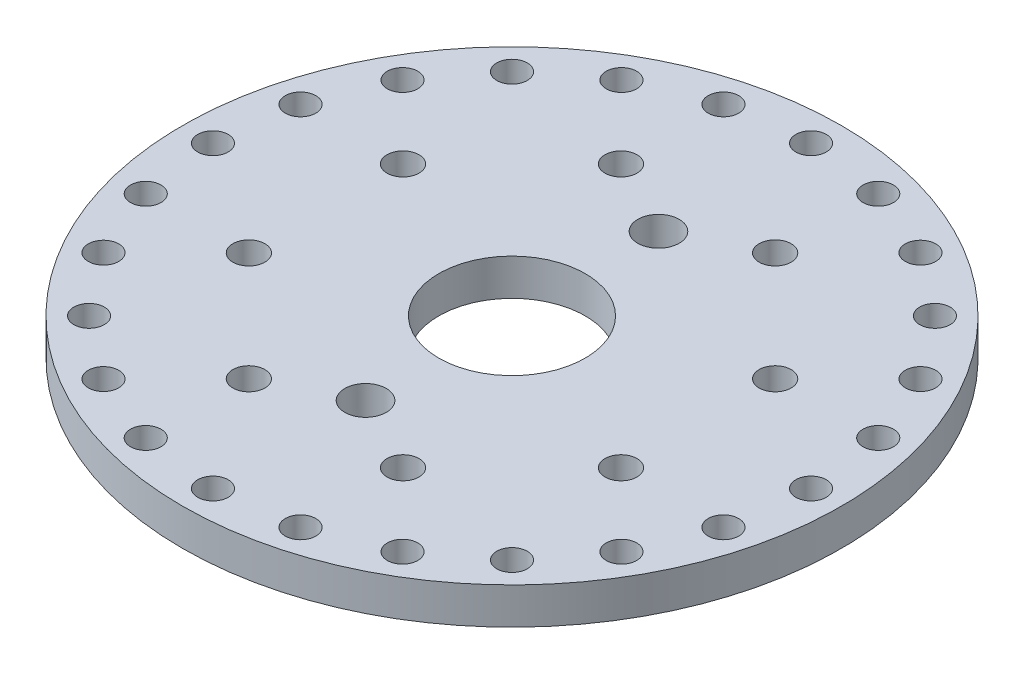
from build123d import *

# Parameters (mm, degrees)
SKETCH8_R           = 27
BOSS_EXTRUDE1_DEPTH = 3
CUT_EXTRUDE1_REACH  = 109.975
SKETCH6_R           = 6
CUT_EXTRUDE2_REACH  = 109.975
SKETCH7_R           = 1.7
CUT_EXTRUDE3_REACH  = 109.975
SKETCH9_R           = 1.25
CUT_EXTRUDE4_REACH  = 109.975
SKETCH11_R          = 1.3125


with BuildPart() as part:
    # Sketch8 → Boss-Extrude1 (new body)
    with BuildSketch(Plane(origin=(0, 0, 0), x_dir=(1, 0, 0), z_dir=(0, 1, 0))):
        with Locations((49.061012395, 49.578499829)):
            Circle(SKETCH8_R)
    extrude(amount=BOSS_EXTRUDE1_DEPTH)

    # Sketch6 → Cut-Extrude1 (cut, up to next)
    with BuildSketch(Plane(origin=(0, 0, 0), x_dir=(1, 0, 0), z_dir=(0, 1, 0)), mode=Mode.PRIVATE) as cut_extrude1_sk1:
        with Locations((49.061012163, 49.578499597)):
            Circle(SKETCH6_R)
    cut_extrude1_tool1 = extrude(cut_extrude1_sk1.sketch, amount=CUT_EXTRUDE1_REACH, mode=Mode.PRIVATE) & part.part
    add(cut_extrude1_tool1.solids().sort_by_distance((49.061012, 0, -49.5785))[0], mode=Mode.SUBTRACT)

    # Sketch7 → Cut-Extrude2 (cut, up to next)
    with BuildSketch(Plane(origin=(0, 0, 0), x_dir=(1, 0, 0), z_dir=(0, 1, 0)), mode=Mode.PRIVATE) as cut_extrude2_sk1:
        with Locations((49.061012163, 61.578499829)):
            Circle(SKETCH7_R)
    cut_extrude2_tool1 = extrude(cut_extrude2_sk1.sketch, amount=CUT_EXTRUDE2_REACH, mode=Mode.PRIVATE) & part.part
    # Sketch7 → Cut-Extrude2 (cut, up to next)
    with BuildSketch(Plane(origin=(0, 0, 0), x_dir=(1, 0, 0), z_dir=(0, 1, 0)), mode=Mode.PRIVATE) as cut_extrude2_sk2:
        with Locations((49.061012163, 37.578499829)):
            Circle(SKETCH7_R)
    cut_extrude2_tool2 = extrude(cut_extrude2_sk2.sketch, amount=CUT_EXTRUDE2_REACH, mode=Mode.PRIVATE) & part.part
    add(cut_extrude2_tool1.solids().sort_by_distance((49.061012, 0, -61.5785))[0], mode=Mode.SUBTRACT)
    add(cut_extrude2_tool2.solids().sort_by_distance((49.061012, 0, -37.5785))[0], mode=Mode.SUBTRACT)

    # Sketch9 → Cut-Extrude3 (cut, up to next)
    with BuildSketch(Plane(origin=(0, 0, 0), x_dir=(1, 0, 0), z_dir=(0, 1, 0)), mode=Mode.PRIVATE) as cut_extrude3_sk1:
        with Locations((49.061012163, 74.078499829)):
            Circle(SKETCH9_R)
    cut_extrude3_tool1 = extrude(cut_extrude3_sk1.sketch, amount=CUT_EXTRUDE3_REACH, mode=Mode.PRIVATE) & part.part
    # Sketch9 → Cut-Extrude3 (cut, up to next)
    with BuildSketch(Plane(origin=(0, 0, 0), x_dir=(1, 0, 0), z_dir=(0, 1, 0)), mode=Mode.PRIVATE) as cut_extrude3_sk2:
        with Locations((55.402078768, 73.243682573)):
            Circle(SKETCH9_R)
    cut_extrude3_tool2 = extrude(cut_extrude3_sk2.sketch, amount=CUT_EXTRUDE3_REACH, mode=Mode.PRIVATE) & part.part
    # Sketch9 → Cut-Extrude3 (cut, up to next)
    with BuildSketch(Plane(origin=(0, 0, 0), x_dir=(1, 0, 0), z_dir=(0, 1, 0)), mode=Mode.PRIVATE) as cut_extrude3_sk3:
        with Locations((61.311012163, 70.796122222)):
            Circle(SKETCH9_R)
    cut_extrude3_tool3 = extrude(cut_extrude3_sk3.sketch, amount=CUT_EXTRUDE3_REACH, mode=Mode.PRIVATE) & part.part
    # Sketch9 → Cut-Extrude3 (cut, up to next)
    with BuildSketch(Plane(origin=(0, 0, 0), x_dir=(1, 0, 0), z_dir=(0, 1, 0)), mode=Mode.PRIVATE) as cut_extrude3_sk4:
        with Locations((66.385128302, 66.902615968)):
            Circle(SKETCH9_R)
    cut_extrude3_tool4 = extrude(cut_extrude3_sk4.sketch, amount=CUT_EXTRUDE3_REACH, mode=Mode.PRIVATE) & part.part
    # Sketch9 → Cut-Extrude3 (cut, up to next)
    with BuildSketch(Plane(origin=(0, 0, 0), x_dir=(1, 0, 0), z_dir=(0, 1, 0)), mode=Mode.PRIVATE) as cut_extrude3_sk5:
        with Locations((70.278634556, 61.828499829)):
            Circle(SKETCH9_R)
    cut_extrude3_tool5 = extrude(cut_extrude3_sk5.sketch, amount=CUT_EXTRUDE3_REACH, mode=Mode.PRIVATE) & part.part
    # Sketch9 → Cut-Extrude3 (cut, up to next)
    with BuildSketch(Plane(origin=(0, 0, 0), x_dir=(1, 0, 0), z_dir=(0, 1, 0)), mode=Mode.PRIVATE) as cut_extrude3_sk6:
        with Locations((72.726194907, 55.919566434)):
            Circle(SKETCH9_R)
    cut_extrude3_tool6 = extrude(cut_extrude3_sk6.sketch, amount=CUT_EXTRUDE3_REACH, mode=Mode.PRIVATE) & part.part
    # Sketch9 → Cut-Extrude3 (cut, up to next)
    with BuildSketch(Plane(origin=(0, 0, 0), x_dir=(1, 0, 0), z_dir=(0, 1, 0)), mode=Mode.PRIVATE) as cut_extrude3_sk7:
        with Locations((73.561012163, 49.578499829)):
            Circle(SKETCH9_R)
    cut_extrude3_tool7 = extrude(cut_extrude3_sk7.sketch, amount=CUT_EXTRUDE3_REACH, mode=Mode.PRIVATE) & part.part
    # Sketch9 → Cut-Extrude3 (cut, up to next)
    with BuildSketch(Plane(origin=(0, 0, 0), x_dir=(1, 0, 0), z_dir=(0, 1, 0)), mode=Mode.PRIVATE) as cut_extrude3_sk8:
        with Locations((72.726194907, 43.237433224)):
            Circle(SKETCH9_R)
    cut_extrude3_tool8 = extrude(cut_extrude3_sk8.sketch, amount=CUT_EXTRUDE3_REACH, mode=Mode.PRIVATE) & part.part
    # Sketch9 → Cut-Extrude3 (cut, up to next)
    with BuildSketch(Plane(origin=(0, 0, 0), x_dir=(1, 0, 0), z_dir=(0, 1, 0)), mode=Mode.PRIVATE) as cut_extrude3_sk9:
        with Locations((70.278634556, 37.328499829)):
            Circle(SKETCH9_R)
    cut_extrude3_tool9 = extrude(cut_extrude3_sk9.sketch, amount=CUT_EXTRUDE3_REACH, mode=Mode.PRIVATE) & part.part
    # Sketch9 → Cut-Extrude3 (cut, up to next)
    with BuildSketch(Plane(origin=(0, 0, 0), x_dir=(1, 0, 0), z_dir=(0, 1, 0)), mode=Mode.PRIVATE) as cut_extrude3_sk10:
        with Locations((66.385128302, 32.25438369)):
            Circle(SKETCH9_R)
    cut_extrude3_tool10 = extrude(cut_extrude3_sk10.sketch, amount=CUT_EXTRUDE3_REACH, mode=Mode.PRIVATE) & part.part
    # Sketch9 → Cut-Extrude3 (cut, up to next)
    with BuildSketch(Plane(origin=(0, 0, 0), x_dir=(1, 0, 0), z_dir=(0, 1, 0)), mode=Mode.PRIVATE) as cut_extrude3_sk11:
        with Locations((61.311012163, 28.360877436)):
            Circle(SKETCH9_R)
    cut_extrude3_tool11 = extrude(cut_extrude3_sk11.sketch, amount=CUT_EXTRUDE3_REACH, mode=Mode.PRIVATE) & part.part
    # Sketch9 → Cut-Extrude3 (cut, up to next)
    with BuildSketch(Plane(origin=(0, 0, 0), x_dir=(1, 0, 0), z_dir=(0, 1, 0)), mode=Mode.PRIVATE) as cut_extrude3_sk12:
        with Locations((55.402078768, 25.913317085)):
            Circle(SKETCH9_R)
    cut_extrude3_tool12 = extrude(cut_extrude3_sk12.sketch, amount=CUT_EXTRUDE3_REACH, mode=Mode.PRIVATE) & part.part
    # Sketch9 → Cut-Extrude3 (cut, up to next)
    with BuildSketch(Plane(origin=(0, 0, 0), x_dir=(1, 0, 0), z_dir=(0, 1, 0)), mode=Mode.PRIVATE) as cut_extrude3_sk13:
        with Locations((49.061012163, 25.078499829)):
            Circle(SKETCH9_R)
    cut_extrude3_tool13 = extrude(cut_extrude3_sk13.sketch, amount=CUT_EXTRUDE3_REACH, mode=Mode.PRIVATE) & part.part
    # Sketch9 → Cut-Extrude3 (cut, up to next)
    with BuildSketch(Plane(origin=(0, 0, 0), x_dir=(1, 0, 0), z_dir=(0, 1, 0)), mode=Mode.PRIVATE) as cut_extrude3_sk14:
        with Locations((42.719945558, 25.913317085)):
            Circle(SKETCH9_R)
    cut_extrude3_tool14 = extrude(cut_extrude3_sk14.sketch, amount=CUT_EXTRUDE3_REACH, mode=Mode.PRIVATE) & part.part
    # Sketch9 → Cut-Extrude3 (cut, up to next)
    with BuildSketch(Plane(origin=(0, 0, 0), x_dir=(1, 0, 0), z_dir=(0, 1, 0)), mode=Mode.PRIVATE) as cut_extrude3_sk15:
        with Locations((36.811012163, 28.360877436)):
            Circle(SKETCH9_R)
    cut_extrude3_tool15 = extrude(cut_extrude3_sk15.sketch, amount=CUT_EXTRUDE3_REACH, mode=Mode.PRIVATE) & part.part
    # Sketch9 → Cut-Extrude3 (cut, up to next)
    with BuildSketch(Plane(origin=(0, 0, 0), x_dir=(1, 0, 0), z_dir=(0, 1, 0)), mode=Mode.PRIVATE) as cut_extrude3_sk16:
        with Locations((31.736896024, 32.25438369)):
            Circle(SKETCH9_R)
    cut_extrude3_tool16 = extrude(cut_extrude3_sk16.sketch, amount=CUT_EXTRUDE3_REACH, mode=Mode.PRIVATE) & part.part
    # Sketch9 → Cut-Extrude3 (cut, up to next)
    with BuildSketch(Plane(origin=(0, 0, 0), x_dir=(1, 0, 0), z_dir=(0, 1, 0)), mode=Mode.PRIVATE) as cut_extrude3_sk17:
        with Locations((27.84338977, 37.328499829)):
            Circle(SKETCH9_R)
    cut_extrude3_tool17 = extrude(cut_extrude3_sk17.sketch, amount=CUT_EXTRUDE3_REACH, mode=Mode.PRIVATE) & part.part
    # Sketch9 → Cut-Extrude3 (cut, up to next)
    with BuildSketch(Plane(origin=(0, 0, 0), x_dir=(1, 0, 0), z_dir=(0, 1, 0)), mode=Mode.PRIVATE) as cut_extrude3_sk18:
        with Locations((25.395829419, 43.237433224)):
            Circle(SKETCH9_R)
    cut_extrude3_tool18 = extrude(cut_extrude3_sk18.sketch, amount=CUT_EXTRUDE3_REACH, mode=Mode.PRIVATE) & part.part
    # Sketch9 → Cut-Extrude3 (cut, up to next)
    with BuildSketch(Plane(origin=(0, 0, 0), x_dir=(1, 0, 0), z_dir=(0, 1, 0)), mode=Mode.PRIVATE) as cut_extrude3_sk19:
        with Locations((24.561012163, 49.578499829)):
            Circle(SKETCH9_R)
    cut_extrude3_tool19 = extrude(cut_extrude3_sk19.sketch, amount=CUT_EXTRUDE3_REACH, mode=Mode.PRIVATE) & part.part
    # Sketch9 → Cut-Extrude3 (cut, up to next)
    with BuildSketch(Plane(origin=(0, 0, 0), x_dir=(1, 0, 0), z_dir=(0, 1, 0)), mode=Mode.PRIVATE) as cut_extrude3_sk20:
        with Locations((25.395829419, 55.919566434)):
            Circle(SKETCH9_R)
    cut_extrude3_tool20 = extrude(cut_extrude3_sk20.sketch, amount=CUT_EXTRUDE3_REACH, mode=Mode.PRIVATE) & part.part
    # Sketch9 → Cut-Extrude3 (cut, up to next)
    with BuildSketch(Plane(origin=(0, 0, 0), x_dir=(1, 0, 0), z_dir=(0, 1, 0)), mode=Mode.PRIVATE) as cut_extrude3_sk21:
        with Locations((27.84338977, 61.828499829)):
            Circle(SKETCH9_R)
    cut_extrude3_tool21 = extrude(cut_extrude3_sk21.sketch, amount=CUT_EXTRUDE3_REACH, mode=Mode.PRIVATE) & part.part
    # Sketch9 → Cut-Extrude3 (cut, up to next)
    with BuildSketch(Plane(origin=(0, 0, 0), x_dir=(1, 0, 0), z_dir=(0, 1, 0)), mode=Mode.PRIVATE) as cut_extrude3_sk22:
        with Locations((31.736896024, 66.902615968)):
            Circle(SKETCH9_R)
    cut_extrude3_tool22 = extrude(cut_extrude3_sk22.sketch, amount=CUT_EXTRUDE3_REACH, mode=Mode.PRIVATE) & part.part
    # Sketch9 → Cut-Extrude3 (cut, up to next)
    with BuildSketch(Plane(origin=(0, 0, 0), x_dir=(1, 0, 0), z_dir=(0, 1, 0)), mode=Mode.PRIVATE) as cut_extrude3_sk23:
        with Locations((36.811012163, 70.796122222)):
            Circle(SKETCH9_R)
    cut_extrude3_tool23 = extrude(cut_extrude3_sk23.sketch, amount=CUT_EXTRUDE3_REACH, mode=Mode.PRIVATE) & part.part
    # Sketch9 → Cut-Extrude3 (cut, up to next)
    with BuildSketch(Plane(origin=(0, 0, 0), x_dir=(1, 0, 0), z_dir=(0, 1, 0)), mode=Mode.PRIVATE) as cut_extrude3_sk24:
        with Locations((42.719945558, 73.243682573)):
            Circle(SKETCH9_R)
    cut_extrude3_tool24 = extrude(cut_extrude3_sk24.sketch, amount=CUT_EXTRUDE3_REACH, mode=Mode.PRIVATE) & part.part
    add(cut_extrude3_tool1.solids().sort_by_distance((49.061012, 0, -74.0785))[0], mode=Mode.SUBTRACT)
    add(cut_extrude3_tool2.solids().sort_by_distance((55.402079, 0, -73.243683))[0], mode=Mode.SUBTRACT)
    add(cut_extrude3_tool3.solids().sort_by_distance((61.311012, 0, -70.796122))[0], mode=Mode.SUBTRACT)
    add(cut_extrude3_tool4.solids().sort_by_distance((66.385128, 0, -66.902616))[0], mode=Mode.SUBTRACT)
    add(cut_extrude3_tool5.solids().sort_by_distance((70.278635, 0, -61.8285))[0], mode=Mode.SUBTRACT)
    add(cut_extrude3_tool6.solids().sort_by_distance((72.726195, 0, -55.919566))[0], mode=Mode.SUBTRACT)
    add(cut_extrude3_tool7.solids().sort_by_distance((73.561012, 0, -49.5785))[0], mode=Mode.SUBTRACT)
    add(cut_extrude3_tool8.solids().sort_by_distance((72.726195, 0, -43.237433))[0], mode=Mode.SUBTRACT)
    add(cut_extrude3_tool9.solids().sort_by_distance((70.278635, 0, -37.3285))[0], mode=Mode.SUBTRACT)
    add(cut_extrude3_tool10.solids().sort_by_distance((66.385128, 0, -32.254384))[0], mode=Mode.SUBTRACT)
    add(cut_extrude3_tool11.solids().sort_by_distance((61.311012, 0, -28.360877))[0], mode=Mode.SUBTRACT)
    add(cut_extrude3_tool12.solids().sort_by_distance((55.402079, 0, -25.913317))[0], mode=Mode.SUBTRACT)
    add(cut_extrude3_tool13.solids().sort_by_distance((49.061012, 0, -25.0785))[0], mode=Mode.SUBTRACT)
    add(cut_extrude3_tool14.solids().sort_by_distance((42.719946, 0, -25.913317))[0], mode=Mode.SUBTRACT)
    add(cut_extrude3_tool15.solids().sort_by_distance((36.811012, 0, -28.360877))[0], mode=Mode.SUBTRACT)
    add(cut_extrude3_tool16.solids().sort_by_distance((31.736896, 0, -32.254384))[0], mode=Mode.SUBTRACT)
    add(cut_extrude3_tool17.solids().sort_by_distance((27.84339, 0, -37.3285))[0], mode=Mode.SUBTRACT)
    add(cut_extrude3_tool18.solids().sort_by_distance((25.395829, 0, -43.237433))[0], mode=Mode.SUBTRACT)
    add(cut_extrude3_tool19.solids().sort_by_distance((24.561012, 0, -49.5785))[0], mode=Mode.SUBTRACT)
    add(cut_extrude3_tool20.solids().sort_by_distance((25.395829, 0, -55.919566))[0], mode=Mode.SUBTRACT)
    add(cut_extrude3_tool21.solids().sort_by_distance((27.84339, 0, -61.8285))[0], mode=Mode.SUBTRACT)
    add(cut_extrude3_tool22.solids().sort_by_distance((31.736896, 0, -66.902616))[0], mode=Mode.SUBTRACT)
    add(cut_extrude3_tool23.solids().sort_by_distance((36.811012, 0, -70.796122))[0], mode=Mode.SUBTRACT)
    add(cut_extrude3_tool24.solids().sort_by_distance((42.719946, 0, -73.243683))[0], mode=Mode.SUBTRACT)

    # Sketch11 → Cut-Extrude4 (cut, up to next)
    with BuildSketch(Plane(origin=(0, 0, 0), x_dir=(1, 0, 0), z_dir=(0, 1, 0)), mode=Mode.PRIVATE) as cut_extrude4_sk1:
        with Locations((55.375288913, 64.822511836)):
            Circle(SKETCH11_R)
    cut_extrude4_tool1 = extrude(cut_extrude4_sk1.sketch, amount=CUT_EXTRUDE4_REACH, mode=Mode.PRIVATE) & part.part
    # Sketch11 → Cut-Extrude4 (cut, up to next)
    with BuildSketch(Plane(origin=(0, 0, 0), x_dir=(1, 0, 0), z_dir=(0, 1, 0)), mode=Mode.PRIVATE) as cut_extrude4_sk2:
        with Locations((64.305024498, 55.892776115)):
            Circle(SKETCH11_R)
    cut_extrude4_tool2 = extrude(cut_extrude4_sk2.sketch, amount=CUT_EXTRUDE4_REACH, mode=Mode.PRIVATE) & part.part
    # Sketch11 → Cut-Extrude4 (cut, up to next)
    with BuildSketch(Plane(origin=(0, 0, 0), x_dir=(1, 0, 0), z_dir=(0, 1, 0)), mode=Mode.PRIVATE) as cut_extrude4_sk3:
        with Locations((64.305024402, 43.264222847)):
            Circle(SKETCH11_R)
    cut_extrude4_tool3 = extrude(cut_extrude4_sk3.sketch, amount=CUT_EXTRUDE4_REACH, mode=Mode.PRIVATE) & part.part
    # Sketch11 → Cut-Extrude4 (cut, up to next)
    with BuildSketch(Plane(origin=(0, 0, 0), x_dir=(1, 0, 0), z_dir=(0, 1, 0)), mode=Mode.PRIVATE) as cut_extrude4_sk4:
        with Locations((55.375288681, 34.334487263)):
            Circle(SKETCH11_R)
    cut_extrude4_tool4 = extrude(cut_extrude4_sk4.sketch, amount=CUT_EXTRUDE4_REACH, mode=Mode.PRIVATE) & part.part
    # Sketch11 → Cut-Extrude4 (cut, up to next)
    with BuildSketch(Plane(origin=(0, 0, 0), x_dir=(1, 0, 0), z_dir=(0, 1, 0)), mode=Mode.PRIVATE) as cut_extrude4_sk5:
        with Locations((42.746735413, 34.334487359)):
            Circle(SKETCH11_R)
    cut_extrude4_tool5 = extrude(cut_extrude4_sk5.sketch, amount=CUT_EXTRUDE4_REACH, mode=Mode.PRIVATE) & part.part
    # Sketch11 → Cut-Extrude4 (cut, up to next)
    with BuildSketch(Plane(origin=(0, 0, 0), x_dir=(1, 0, 0), z_dir=(0, 1, 0)), mode=Mode.PRIVATE) as cut_extrude4_sk6:
        with Locations((33.816999829, 43.264223079)):
            Circle(SKETCH11_R)
    cut_extrude4_tool6 = extrude(cut_extrude4_sk6.sketch, amount=CUT_EXTRUDE4_REACH, mode=Mode.PRIVATE) & part.part
    # Sketch11 → Cut-Extrude4 (cut, up to next)
    with BuildSketch(Plane(origin=(0, 0, 0), x_dir=(1, 0, 0), z_dir=(0, 1, 0)), mode=Mode.PRIVATE) as cut_extrude4_sk7:
        with Locations((33.816999925, 55.892776347)):
            Circle(SKETCH11_R)
    cut_extrude4_tool7 = extrude(cut_extrude4_sk7.sketch, amount=CUT_EXTRUDE4_REACH, mode=Mode.PRIVATE) & part.part
    # Sketch11 → Cut-Extrude4 (cut, up to next)
    with BuildSketch(Plane(origin=(0, 0, 0), x_dir=(1, 0, 0), z_dir=(0, 1, 0)), mode=Mode.PRIVATE) as cut_extrude4_sk8:
        with Locations((42.746735645, 64.822511932)):
            Circle(SKETCH11_R)
    cut_extrude4_tool8 = extrude(cut_extrude4_sk8.sketch, amount=CUT_EXTRUDE4_REACH, mode=Mode.PRIVATE) & part.part
    add(cut_extrude4_tool1.solids().sort_by_distance((55.375289, 0, -64.822512))[0], mode=Mode.SUBTRACT)
    add(cut_extrude4_tool2.solids().sort_by_distance((64.305024, 0, -55.892776))[0], mode=Mode.SUBTRACT)
    add(cut_extrude4_tool3.solids().sort_by_distance((64.305024, 0, -43.264223))[0], mode=Mode.SUBTRACT)
    add(cut_extrude4_tool4.solids().sort_by_distance((55.375289, 0, -34.334487))[0], mode=Mode.SUBTRACT)
    add(cut_extrude4_tool5.solids().sort_by_distance((42.746735, 0, -34.334487))[0], mode=Mode.SUBTRACT)
    add(cut_extrude4_tool6.solids().sort_by_distance((33.817, 0, -43.264223))[0], mode=Mode.SUBTRACT)
    add(cut_extrude4_tool7.solids().sort_by_distance((33.817, 0, -55.892776))[0], mode=Mode.SUBTRACT)
    add(cut_extrude4_tool8.solids().sort_by_distance((42.746736, 0, -64.822512))[0], mode=Mode.SUBTRACT)


solid = part.part
